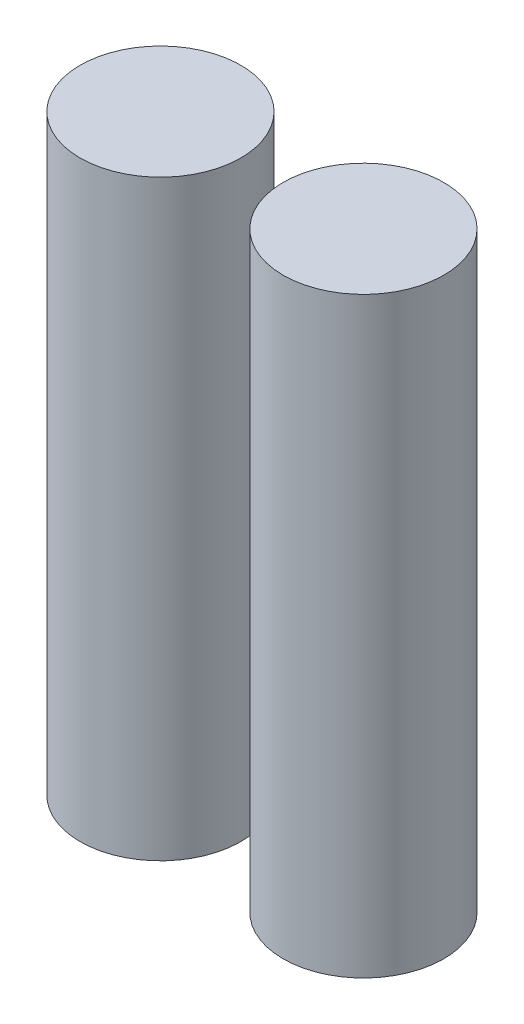
from build123d import *

# Parameters (mm, degrees)
SKETCH2_R             = 9.5
BOSS_EXTRUDE1_DEPTH   = 70
BOSS_EXTRUDE1_2_DEPTH = 70


with BuildPart() as part:
    # Sketch2 → Boss-Extrude1 (new body)
    with BuildSketch(Plane(origin=(0, 0, 0), x_dir=(1, 0, 0), z_dir=(0, 1, 0))):
        with Locations((-12, 0)):
            Circle(SKETCH2_R)
    extrude(amount=BOSS_EXTRUDE1_DEPTH)


with BuildPart() as body_2:
    # Sketch2 → Boss-Extrude1 2 (new body)
    with BuildSketch(Plane(origin=(0, 0, 0), x_dir=(1, 0, 0), z_dir=(0, 1, 0))):
        with Locations((12, 0)):
            Circle(SKETCH2_R)
    extrude(amount=BOSS_EXTRUDE1_2_DEPTH)


solid = Compound([part.part, body_2.part])
